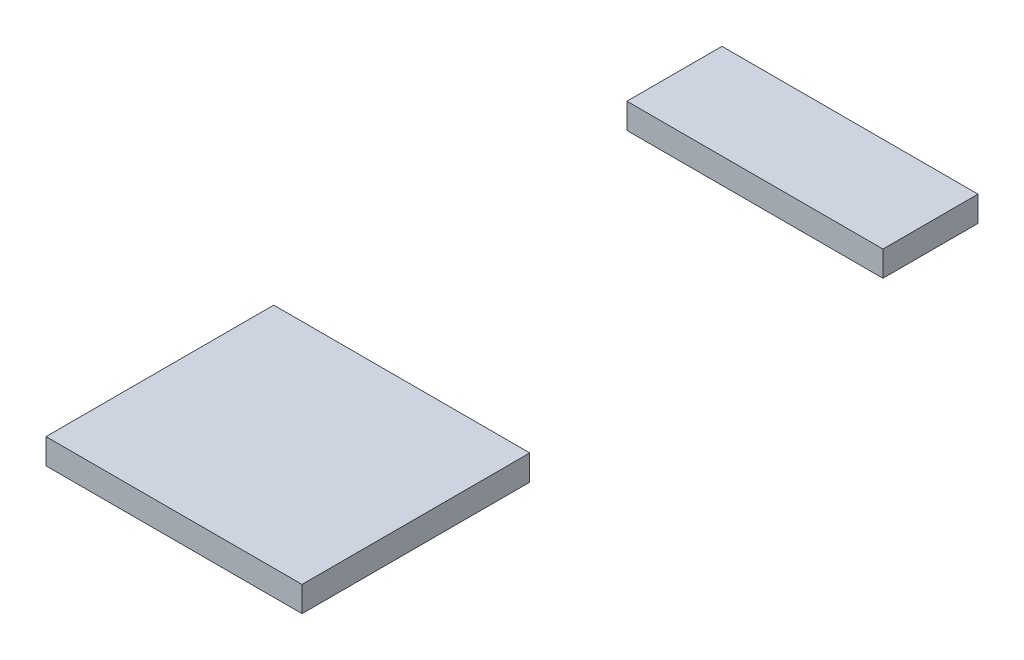
from build123d import *

# Parameters (mm, degrees)
SKETCH1_W             = 30.3
SKETCH1_H             = 26.95
BOSS_EXTRUDE1_DEPTH   = 3
SKETCH1_H_2           = 11.25
BOSS_EXTRUDE1_2_DEPTH = 3


with BuildPart() as part:
    # Sketch1 → Boss-Extrude1 (new body)
    with BuildSketch(Plane(origin=(0, 0, 0), x_dir=(1, 0, 0), z_dir=(0, 1, 0))):
        with Locations((15.15, 13.475)):
            Rectangle(SKETCH1_W, SKETCH1_H)
    extrude(amount=-BOSS_EXTRUDE1_DEPTH)


with BuildPart() as body_2:
    # Sketch1 → Boss-Extrude1 2 (new body)
    with BuildSketch(Plane(origin=(0, 0, 0), x_dir=(1, 0, 0), z_dir=(0, 1, 0))):
        with Locations((15.15, 74.375)):
            Rectangle(SKETCH1_W, SKETCH1_H_2)
    extrude(amount=-BOSS_EXTRUDE1_2_DEPTH)


solid = Compound([part.part, body_2.part])
